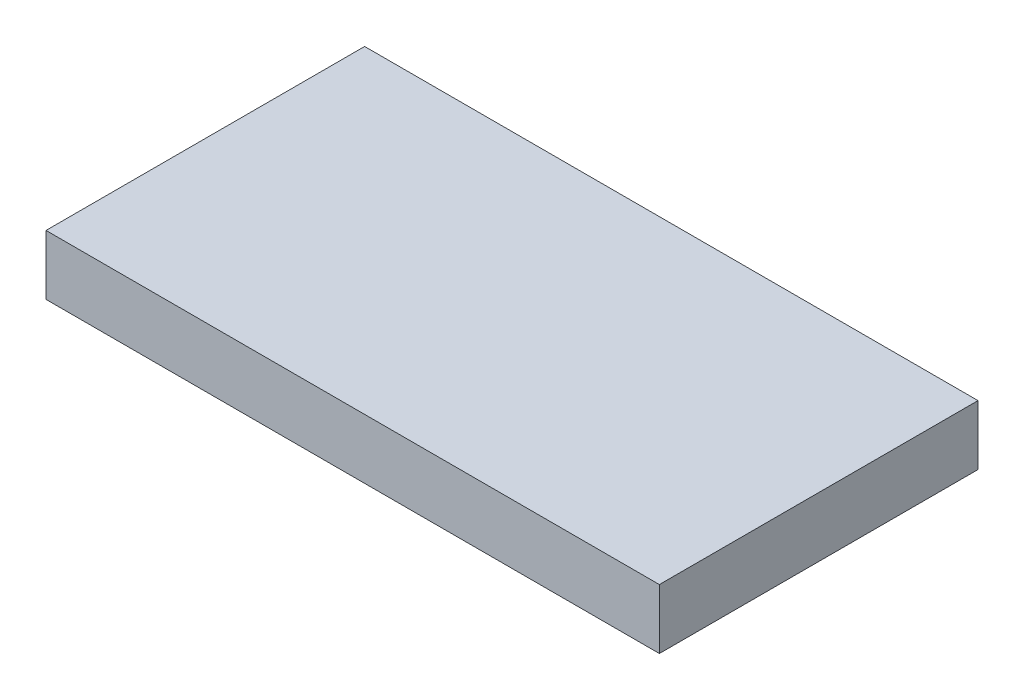
from build123d import *

# Parameters (mm, degrees)
SKETCH1_W           = 1.54
SKETCH1_H           = 0.8
BOSS_EXTRUDE1_DEPTH = 0.15


with BuildPart() as part:
    # Sketch1 → Boss-Extrude1 (new body)
    with BuildSketch(Plane(origin=(0, 0, 0), x_dir=(1, 0, 0), z_dir=(0, 1, 0))):
        Rectangle(SKETCH1_W, SKETCH1_H)
    extrude(amount=BOSS_EXTRUDE1_DEPTH)


solid = part.part
